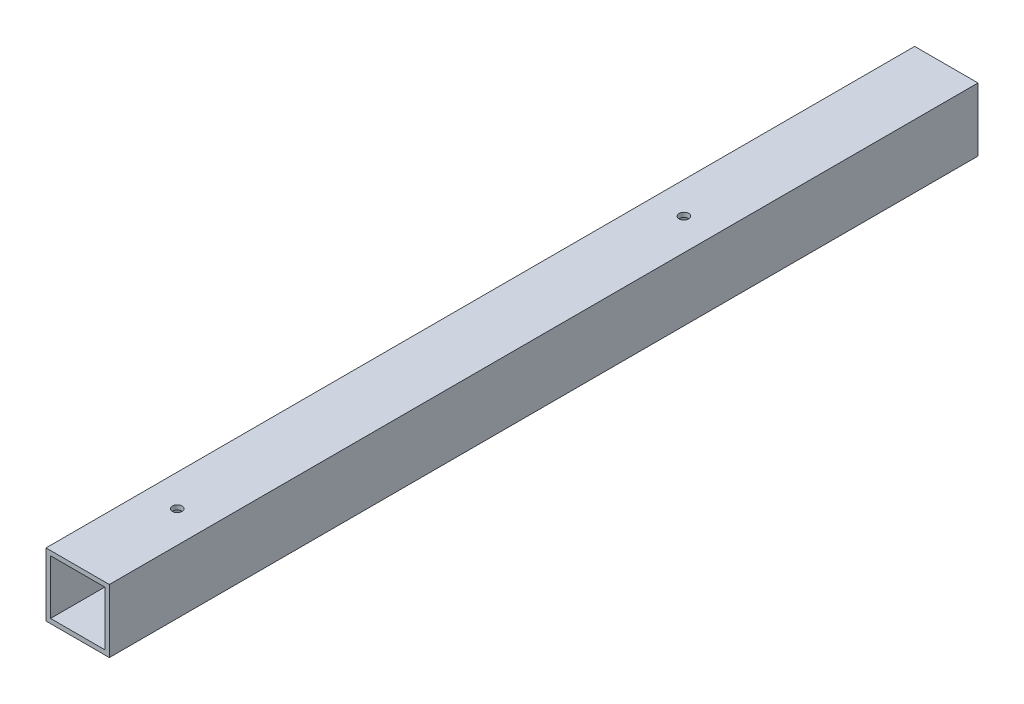
from build123d import *

# Parameters (mm, degrees)
SKETCH1_W               = 44.45
SKETCH1_H               = 44.45
SKETCH1_W_2             = 38.1
SKETCH1_H_2             = 38.1
BOSS_EXTRUDE1_DEPTH     = 609.6
F_1_4_CLEARANCE_HOLE1_D = 6.7564


with BuildPart() as part:
    # Sketch1 → Boss-Extrude1 (new body)
    with BuildSketch(Plane.XY):
        with Locations((22.225, 22.225)):
            Rectangle(SKETCH1_W, SKETCH1_H)
        with Locations((22.225, 22.225)):
            Rectangle(SKETCH1_W_2, SKETCH1_H_2, mode=Mode.SUBTRACT)
    extrude(amount=BOSS_EXTRUDE1_DEPTH)

    # 1/4 Clearance Hole1 (through all)
    with Locations(Plane(origin=(0, 44.45, 0), x_dir=(1, 0, 0), z_dir=(0, 1, 0))):
        with Locations((22.225, -539.75), (22.225, -184.15)):
            Hole(F_1_4_CLEARANCE_HOLE1_D / 2)


solid = part.part
